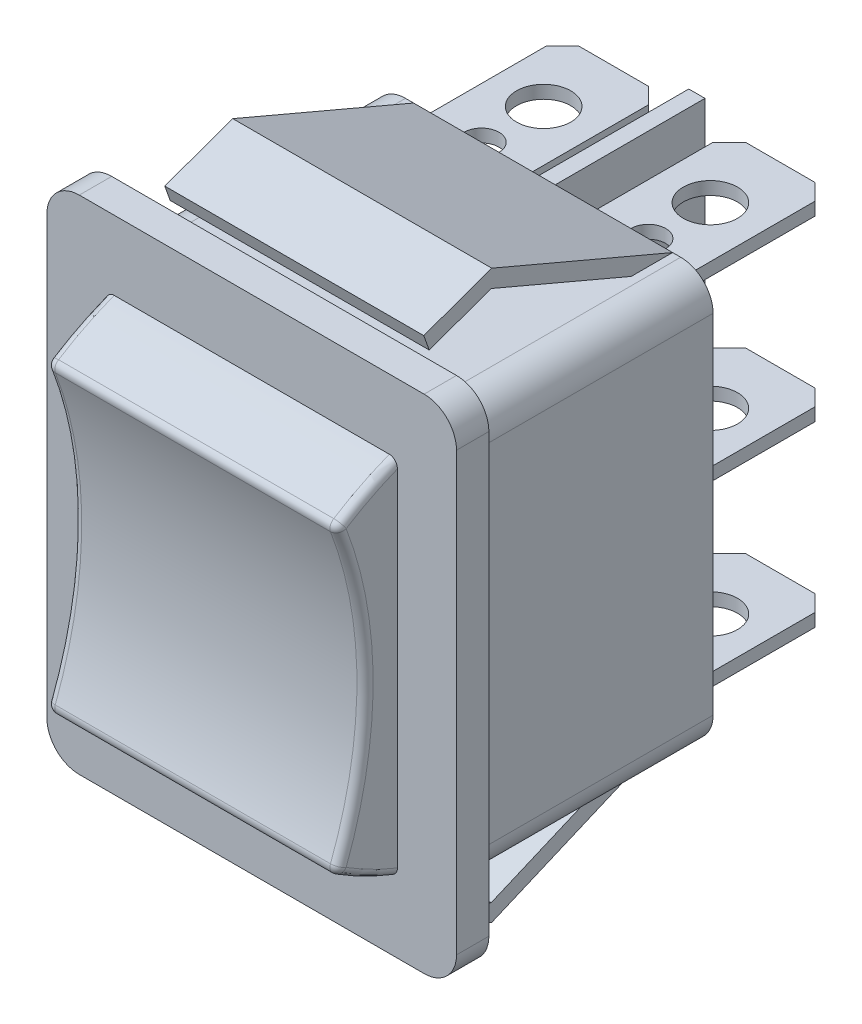
from build123d import *

# Parameters (mm, degrees)
SKETCH2_W           = 25.3
SKETCH2_H           = 31
BOSS_EXTRUDE1_DEPTH = 2
SKETCH3_W           = 21
SKETCH3_H           = 25.5
BOSS_EXTRUDE2_DEPTH = 16
SKETCH4_W           = 20.928635558
SKETCH4_H           = 25
BOSS_EXTRUDE3_DEPTH = 0.5
SKETCH5_W           = 6.3
SKETCH5_H           = 12.271886547
SKETCH5_R           = 1.075894355
SKETCH5_R_2         = 1.675427573
BOSS_EXTRUDE4_DEPTH = 0.4
CHAMFER1_SIZE       = 1
LPATTERN1_COUNT     = 2
LPATTERN1_PITCH     = 11
LPATTERN1_2_COUNT   = 2
LPATTERN1_2_PITCH   = 11
EXTRUDE_THIN1_DEPTH = 8
FILLET1_R           = 2
BOSS_EXTRUDE5_DEPTH = 9
FILLET2_R           = 0.5


with BuildPart() as part:
    # Sketch2 → Boss-Extrude1 (new body)
    with BuildSketch(Plane.XY):
        Rectangle(SKETCH2_W, SKETCH2_H)
    extrude(amount=BOSS_EXTRUDE1_DEPTH)

    # Sketch3 → Boss-Extrude2 (add)
    with BuildSketch(Plane.XY):
        Rectangle(SKETCH3_W, SKETCH3_H)
    extrude(amount=-BOSS_EXTRUDE2_DEPTH)

    # Sketch4 → Boss-Extrude3 (add, symmetric)
    with BuildSketch(Plane(origin=(0, 0, 0), x_dir=(0, 0, -1), z_dir=(1, 0, 0))):
        with Locations((15.035682221, 0)):
            Rectangle(SKETCH4_W, SKETCH4_H)
    extrude(amount=BOSS_EXTRUDE3_DEPTH, both=True)

    # Sketch7 → Extrude-Thin1 (add, symmetric)
    with BuildSketch(Plane(origin=(0, 0, 0), x_dir=(0, 0, -1), z_dir=(1, 0, 0))):
        Polygon((16, -12.75), (4.827820182, -17.5), (0.627452347, -15.993754846), (0.965003581, -15.052447688), (4.796845129, -16.426539909), (15.608732132, -11.829723163), align=None)
    extrude_thin1 = extrude(amount=EXTRUDE_THIN1_DEPTH, both=True)

    # Mirror2: Extrude-Thin1 across plane
    add(extrude_thin1.mirror(Plane.ZX))

    # Fillet1
    fillet1_edges = [part.edges().sort_by_distance(p)[0] for p in [
        (10.5, 12.75, -8),
        (10.5, -12.75, -8),
        (-10.5, -12.75, -8),
        (-10.5, 12.75, -8),
        (12.65, -15.5, 1),
        (-12.65, -15.5, 1),
        (-12.65, 15.5, 1),
        (12.65, 15.5, 1),
    ]]
    fillet(fillet1_edges, radius=FILLET1_R)


with BuildPart() as body_2:
    # Sketch5 → Boss-Extrude4 (new body, symmetric)
    with BuildSketch(Plane(origin=(0, 0, 0), x_dir=(1, 0, 0), z_dir=(0, 1, 0))):
        with Locations((5.15, 19.364056726)):
            Rectangle(SKETCH5_W, SKETCH5_H)
        with Locations((5.15, 17.349955158)):
            Circle(SKETCH5_R, mode=Mode.SUBTRACT)
        with Locations((5.15, 21.184469091)):
            Circle(SKETCH5_R_2, mode=Mode.SUBTRACT)
    extrude(amount=BOSS_EXTRUDE4_DEPTH, both=True)

    # Chamfer1
    chamfer1_edges = [body_2.edges().sort_by_distance(p)[0] for p in [
        (2, 0, -25.5),
        (8.3, 0, -25.5),
    ]]
    chamfer(chamfer1_edges, length=CHAMFER1_SIZE)


with BuildPart() as lpattern1_1:
    # LPattern1: pattern copy
    add(body_2.part.moved(Location(Vector(0, -1, 0) * (1 * LPATTERN1_PITCH))))


with BuildPart() as lpattern1_2_1:
    # LPattern1 2: pattern copy
    add(body_2.part.moved(Location(Vector(0, 1, 0) * (1 * LPATTERN1_2_PITCH))))


with BuildPart() as body_5:
    # Mirror1: mirrored copy
    add(lpattern1_2_1.part.mirror(Plane(origin=(0, 0, 0), x_dir=(0, 0, 1), z_dir=(1, 0, 0))))


with BuildPart() as body_6:
    # Mirror1 2: mirrored copy
    add(lpattern1_1.part.mirror(Plane(origin=(0, 0, 0), x_dir=(0, 0, 1), z_dir=(1, 0, 0))))


with BuildPart() as body_7:
    # Mirror1 3: mirrored copy
    add(body_2.part.mirror(Plane(origin=(0, 0, 0), x_dir=(0, 0, 1), z_dir=(1, 0, 0))))


with BuildPart() as body_8:
    # Sketch8 → Boss-Extrude5 (new body, symmetric)
    with BuildSketch(Plane(origin=(0, 0, 0), x_dir=(0, 0, -1), z_dir=(1, 0, 0))):
        with BuildLine():
            Line((-2, -11.210063531), (-2, 11.210063531))
            ThreePointArc((-2, 11.210063531), (-3.943805775, 10.338071393), (-5.781353655, 9.260031984))
            ThreePointArc((-5.781353655, 9.260031984), (-4.000927331, 0), (-5.781353655, -9.260031984))
            ThreePointArc((-5.781353655, -9.260031984), (-3.943805775, -10.338071393), (-2, -11.210063531))
        make_face()
    extrude(amount=BOSS_EXTRUDE5_DEPTH, both=True)

    # Fillet2
    fillet2_edges = [body_8.edges().sort_by_distance(p)[0] for p in [
        (9, -10.338071393, 3.943805775),
        (9, 10.338071393, 3.943805775),
        (-9, -10.338071393, 3.943805775),
        (-9, 0, 4.000927331),
        (-9, 10.338071393, 3.943805775),
        (9, 0, 4.000927331),
        (0, -9.260031984, 5.781353655),
        (0, 9.260031984, 5.781353655),
    ]]
    fillet(fillet2_edges, radius=FILLET2_R)


solid = Compound([part.part, body_2.part, lpattern1_1.part, lpattern1_2_1.part, body_5.part, body_6.part, body_7.part, body_8.part])
